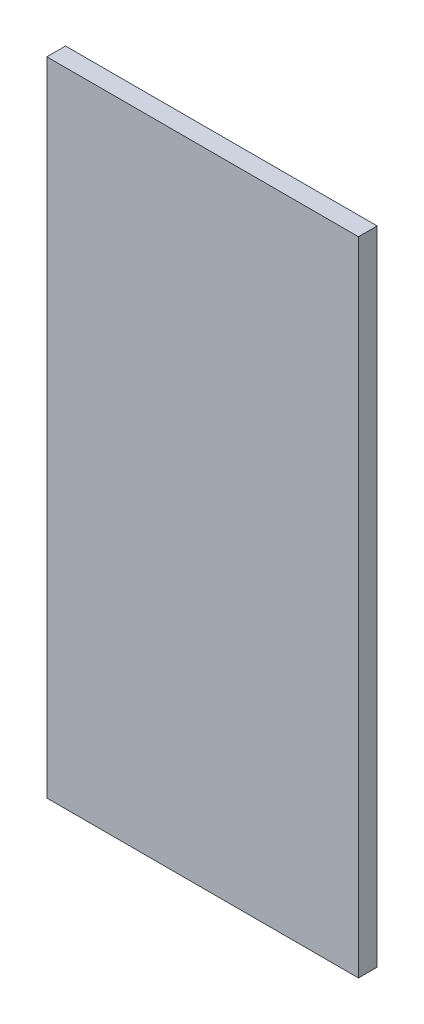
from build123d import *

# Parameters (mm, degrees)
SKETCH1_W           = 100
SKETCH1_H           = 206
BOSS_EXTRUDE1_DEPTH = 6


with BuildPart() as part:
    # Sketch1 → Boss-Extrude1 (new body)
    with BuildSketch(Plane.XY):
        with Locations((40, 96.427419355)):
            Rectangle(SKETCH1_W, SKETCH1_H)
    extrude(amount=BOSS_EXTRUDE1_DEPTH)


solid = part.part
